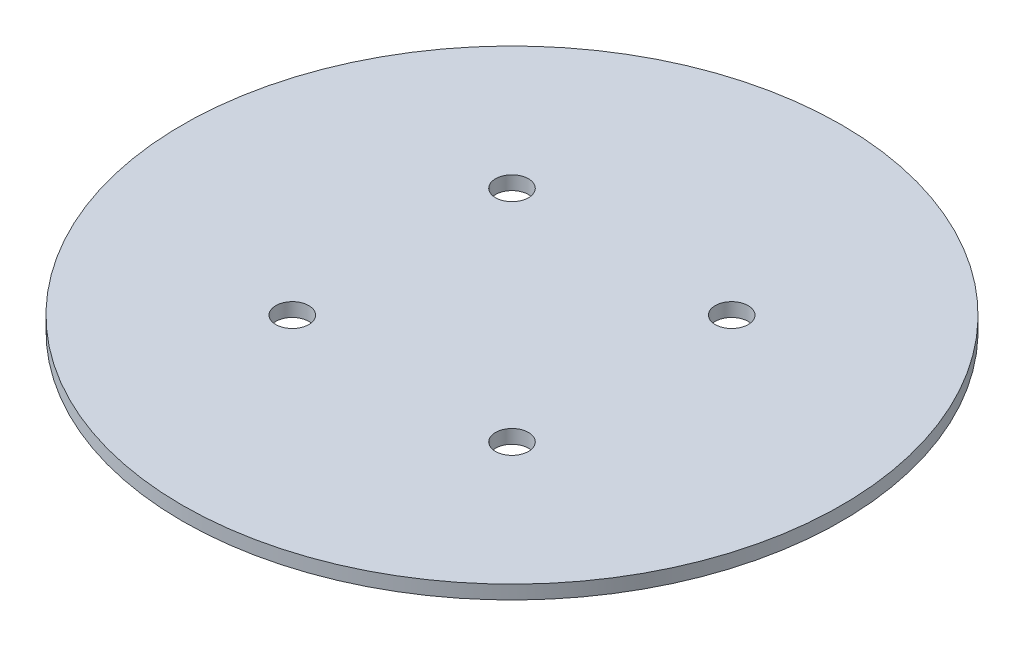
from build123d import *

# Parameters (mm, degrees)
SKETCH1_R           = 76.2
SKETCH1_R_2         = 3.81
BOSS_EXTRUDE1_DEPTH = 3.175


with BuildPart() as part:
    # Sketch1 → Boss-Extrude1 (new body)
    with BuildSketch(Plane(origin=(0, 0, 0), x_dir=(1, 0, 0), z_dir=(0, 1, 0))):
        Circle(SKETCH1_R)
        with Locations((-25.4, 25.4)):
            Circle(SKETCH1_R_2, mode=Mode.SUBTRACT)
        with Locations((-25.4, -25.4)):
            Circle(SKETCH1_R_2, mode=Mode.SUBTRACT)
        with Locations((25.4, -25.4)):
            Circle(SKETCH1_R_2, mode=Mode.SUBTRACT)
        with Locations((25.4, 25.4)):
            Circle(SKETCH1_R_2, mode=Mode.SUBTRACT)
    extrude(amount=BOSS_EXTRUDE1_DEPTH)


solid = part.part
